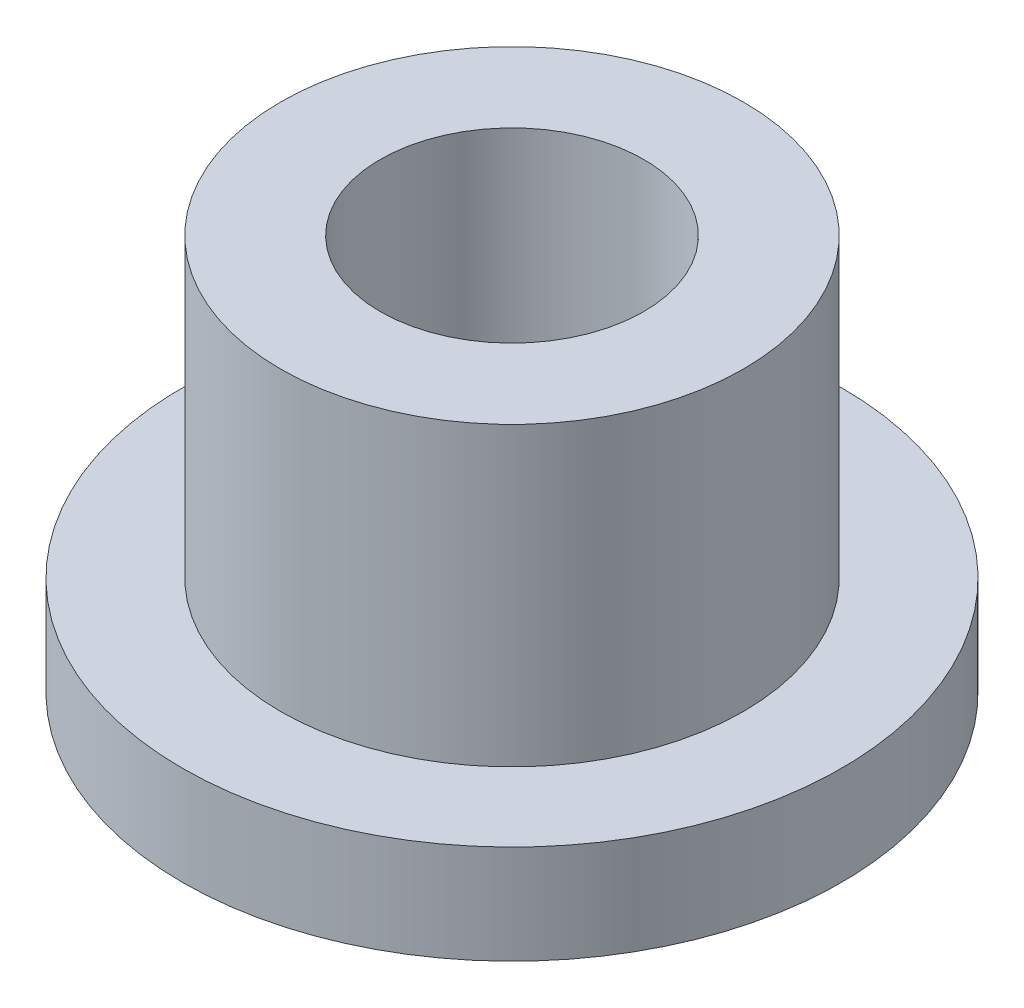
from build123d import *

# Parameters (mm, degrees)
SKETCH5_R                = 3.51
SKETCH5_R_2              = 2
BOSS_EXTRUDE1_DEPTH      = 3
BOSS_EXTRUDE1_DEPTH_BACK = 3
BOSS_EXTRUDE2_START      = -3
SKETCH7_R                = 5
SKETCH7_R_2              = 3.51
BOSS_EXTRUDE2_DEPTH      = 1.5


with BuildPart() as part:
    # Sketch5 → Boss-Extrude1 (new body, two sides)
    with BuildSketch(Plane(origin=(0, 0, 0), x_dir=(1, 0, 0), z_dir=(0, 1, 0))) as boss_extrude1_sk:
        Circle(SKETCH5_R)
        Circle(SKETCH5_R_2, mode=Mode.SUBTRACT)
    extrude(amount=BOSS_EXTRUDE1_DEPTH)
    extrude(boss_extrude1_sk.sketch, amount=-BOSS_EXTRUDE1_DEPTH_BACK)

    # Sketch7 → Boss-Extrude2 (add)
    with BuildSketch(Plane(origin=(0, 0, 0), x_dir=(1, 0, 0), z_dir=(0, 1, 0)).offset(BOSS_EXTRUDE2_START)):
        Circle(SKETCH7_R)
        Circle(SKETCH7_R_2, mode=Mode.SUBTRACT)
    extrude(amount=BOSS_EXTRUDE2_DEPTH)


solid = part.part
